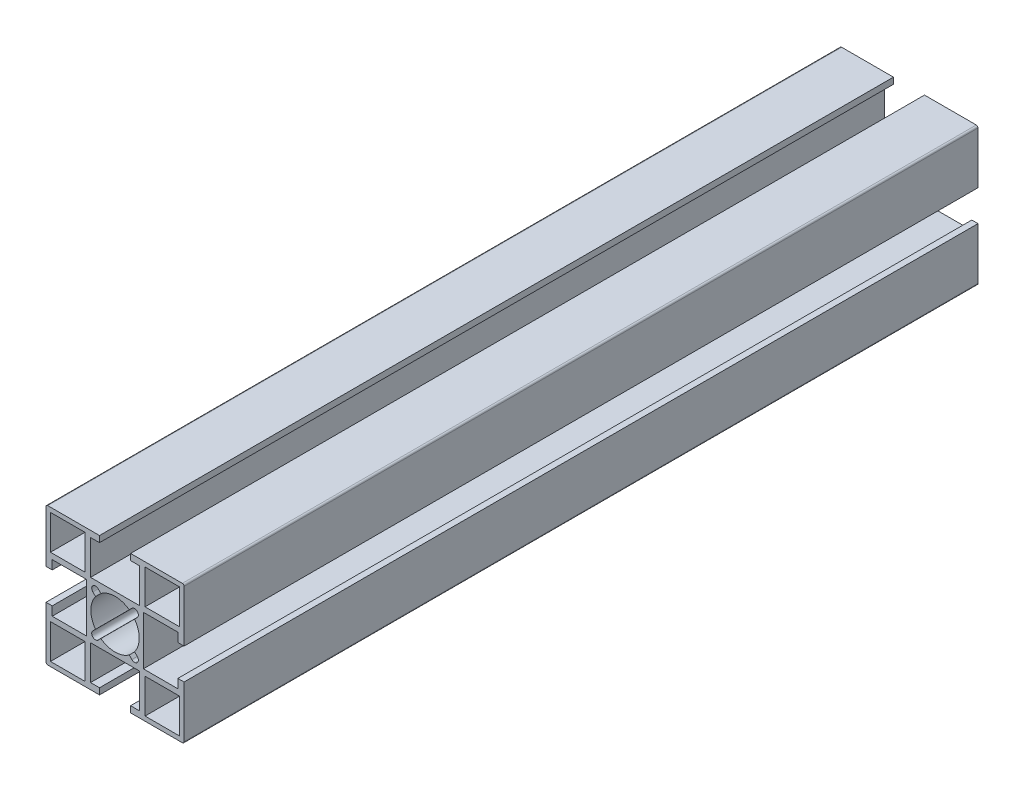
from build123d import *

# Parameters (mm, degrees)
SKETCH1_W                 = 10
SKETCH1_H                 = 10
F_40_X_40A_X_R0_5_1_DEPTH = 230


with BuildPart() as part:
    # Sketch1 → 铝型材 40 X 40A X R0.5(1) (new body)
    with BuildSketch(Plane.YX):
        with BuildLine():
            Line((-19.5, 20), (-4.5, 20))
            Line((-4.5, 20), (-4.5, 18.2))
            Line((-4.5, 18.2), (-7.1, 18.2))
            Line((-7.1, 18.2), (-7.1, 8.2))
            Line((-7.1, 8.2), (7.1, 8.2))
            Line((7.1, 8.2), (7.1, 18.2))
            Line((7.1, 18.2), (4.5, 18.2))
            Line((4.5, 18.2), (4.5, 20))
            Line((4.5, 20), (19.5, 20))
            ThreePointArc((19.5, 20), (19.853553391, 19.853553391), (20, 19.5))
            Line((20, 19.5), (20, 4.5))
            Line((20, 4.5), (18.2, 4.5))
            Line((18.2, 4.5), (18.2, 7.1))
            Line((18.2, 7.1), (8.2, 7.1))
            Line((8.2, 7.1), (8.2, -7.1))
            Line((8.2, -7.1), (18.2, -7.1))
            Line((18.2, -7.1), (18.2, -4.5))
            Line((18.2, -4.5), (20, -4.5))
            Line((20, -4.5), (20, -19.5))
            ThreePointArc((20, -19.5), (19.853553391, -19.853553391), (19.5, -20))
            Line((19.5, -20), (4.5, -20))
            Line((4.5, -20), (4.5, -18.2))
            Line((4.5, -18.2), (7.1, -18.2))
            Line((7.1, -18.2), (7.1, -8.2))
            Line((7.1, -8.2), (-7.1, -8.2))
            Line((-7.1, -8.2), (-7.1, -18.2))
            Line((-7.1, -18.2), (-4.5, -18.2))
            Line((-4.5, -18.2), (-4.5, -20))
            Line((-4.5, -20), (-19.5, -20))
            ThreePointArc((-19.5, -20), (-19.853553391, -19.853553391), (-20, -19.5))
            Line((-20, -19.5), (-20, -4.5))
            Line((-20, -4.5), (-18.2, -4.5))
            Line((-18.2, -4.5), (-18.2, -7.1))
            Line((-18.2, -7.1), (-8.2, -7.1))
            Line((-8.2, -7.1), (-8.2, 7.1))
            Line((-8.2, 7.1), (-18.2, 7.1))
            Line((-18.2, 7.1), (-18.2, 4.5))
            Line((-18.2, 4.5), (-20, 4.5))
            Line((-20, 4.5), (-20, 19.5))
            ThreePointArc((-20, 19.5), (-19.853553391, 19.853553391), (-19.5, 20))
        make_face()
        with BuildLine():
            Line((-4.87903679, 6.434671709), (-4.110433762, 5.66606868))
            ThreePointArc((-4.110433762, 5.66606868), (0, 7), (4.110433762, 5.66606868))
            Line((4.110433762, 5.66606868), (4.87903679, 6.434671709))
            ThreePointArc((4.87903679, 6.434671709), (6.434671709, 6.434671709), (6.434671709, 4.87903679))
            Line((6.434671709, 4.87903679), (5.66606868, 4.110433762))
            ThreePointArc((5.66606868, 4.110433762), (7, 0), (5.66606868, -4.110433762))
            Line((5.66606868, -4.110433762), (6.434671709, -4.87903679))
            ThreePointArc((6.434671709, -4.87903679), (6.434671709, -6.434671709), (4.87903679, -6.434671709))
            Line((4.87903679, -6.434671709), (4.110433762, -5.66606868))
            ThreePointArc((4.110433762, -5.66606868), (0, -7), (-4.110433762, -5.66606868))
            Line((-4.110433762, -5.66606868), (-4.87903679, -6.434671709))
            ThreePointArc((-4.87903679, -6.434671709), (-6.434671709, -6.434671709), (-6.434671709, -4.87903679))
            Line((-6.434671709, -4.87903679), (-5.66606868, -4.110433762))
            ThreePointArc((-5.66606868, -4.110433762), (-7, 0), (-5.66606868, 4.110433762))
            Line((-5.66606868, 4.110433762), (-6.434671709, 4.87903679))
            ThreePointArc((-6.434671709, 4.87903679), (-6.434671709, 6.434671709), (-4.87903679, 6.434671709))
        make_face(mode=Mode.SUBTRACT)
        with Locations((-13.7, 13.7)):
            Rectangle(SKETCH1_W, SKETCH1_H, mode=Mode.SUBTRACT)
        with Locations((13.7, 13.7)):
            Rectangle(SKETCH1_W, SKETCH1_H, mode=Mode.SUBTRACT)
        with Locations((13.7, -13.7)):
            Rectangle(SKETCH1_W, SKETCH1_H, mode=Mode.SUBTRACT)
        with Locations((-13.7, -13.7)):
            Rectangle(SKETCH1_W, SKETCH1_H, mode=Mode.SUBTRACT)
    extrude(amount=F_40_X_40A_X_R0_5_1_DEPTH)


solid = part.part
